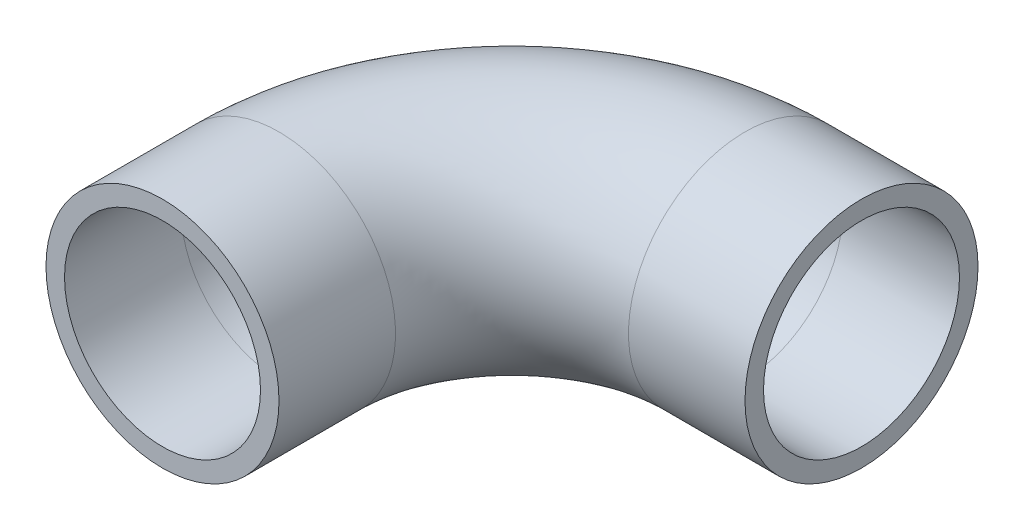
from build123d import *

# Parameters (mm, degrees)
SKETCH1_R   = 12.7
SKETCH1_R_2 = 10.6807


with BuildPart() as part:
    # Sweep7: sweep along a path in Sketch15
    with BuildLine(Plane(origin=(0, 0, 0), x_dir=(1, 0, 0), z_dir=(0, 1, 0))) as sweep7_path:
        Line((0, 0), (0, 12.7))
        ThreePointArc((0, 12.7), (7.439487758, 30.660512242), (25.4, 38.1))
        Line((25.4, 38.1), (38.1, 38.1))
    # Sketch1 → Sweep7 (sweep)
    with BuildSketch(Plane.XY):
        Circle(SKETCH1_R)
        Circle(SKETCH1_R_2, mode=Mode.SUBTRACT)
    sweep(path=sweep7_path.line)


solid = part.part
